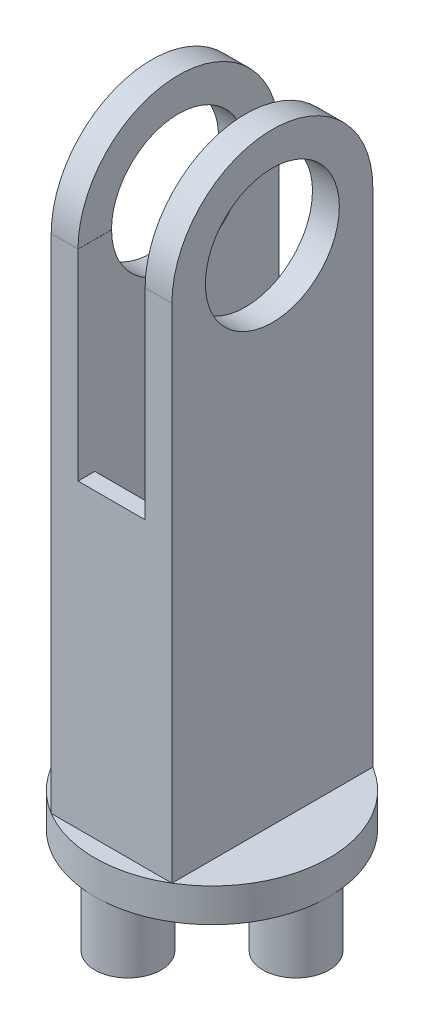
from build123d import *

# Parameters (mm, degrees)
SKETCH1_R            = 35
BOSS_EXTRUDE1_DEPTH  = 10
SKETCH3_R            = 9.9
BOSS_EXTRUDE2_DEPTH  = 19
SKETCH4_W            = 36.055512754
SKETCH4_H            = 60
BOSS_EXTRUDE8_DEPTH  = 150
SKETCH11_W           = 20
SKETCH11_H           = 60
CUT_EXTRUDE2_DEPTH   = 60
SKETCH12_W           = 20
SKETCH12_H           = 50
CUT_EXTRUDE3_DEPTH   = 90
SKETCH13_R           = 30
BOSS_EXTRUDE9_DEPTH  = 8
SKETCH14_R           = 30
BOSS_EXTRUDE10_DEPTH = 8
SKETCH15_R           = 20
CUT_EXTRUDE4_DEPTH   = 97


with BuildPart() as part:
    # Sketch1 → Boss-Extrude1 (new body)
    with BuildSketch(Plane(origin=(0, 0, 0), x_dir=(1, 0, 0), z_dir=(0, 1, 0))):
        Circle(SKETCH1_R)
    extrude(amount=BOSS_EXTRUDE1_DEPTH)

    # Sketch3 → Boss-Extrude2 (add)
    with BuildSketch(Plane.XZ):
        with Locations((25.1, 0)):
            Circle(SKETCH3_R)
        with Locations((0, -25.1)):
            Circle(SKETCH3_R)
        with Locations((-25.1, 0)):
            Circle(SKETCH3_R)
        with Locations((0, 25.1)):
            Circle(SKETCH3_R)
    extrude(amount=BOSS_EXTRUDE2_DEPTH)

    # Sketch4 → Boss-Extrude8 (add)
    with BuildSketch(Plane(origin=(0, 10, 0), x_dir=(1, 0, 0), z_dir=(0, 1, 0))):
        Rectangle(SKETCH4_W, SKETCH4_H)
    extrude(amount=BOSS_EXTRUDE8_DEPTH)

    # Sketch11 → Cut-Extrude2 (cut)
    with BuildSketch(Plane(origin=(0, 160, 0), x_dir=(1, 0, 0), z_dir=(0, 1, 0))):
        Rectangle(SKETCH11_W, SKETCH11_H)
    extrude(amount=-CUT_EXTRUDE2_DEPTH, mode=Mode.SUBTRACT)

    # Sketch12 → Cut-Extrude3 (cut)
    with BuildSketch(Plane(origin=(0, 100, 0), x_dir=(1, 0, 0), z_dir=(0, 1, 0))):
        Rectangle(SKETCH12_W, SKETCH12_H)
    extrude(amount=-CUT_EXTRUDE3_DEPTH, mode=Mode.SUBTRACT)

    # Sketch13 → Boss-Extrude9 (add)
    with BuildSketch(Plane.ZY.offset(18.027756377)):
        with Locations((0, 160)):
            Circle(SKETCH13_R)
    extrude(amount=-BOSS_EXTRUDE9_DEPTH)

    # Sketch14 → Boss-Extrude10 (add)
    with BuildSketch(Plane(origin=(18.027756377, 0, 0), x_dir=(0, 0, -1), z_dir=(1, 0, 0))):
        with Locations((0, 160)):
            Circle(SKETCH14_R)
    extrude(amount=-BOSS_EXTRUDE10_DEPTH)

    # Sketch15 → Cut-Extrude4 (cut)
    with BuildSketch(Plane(origin=(18.027756377, 0, 0), x_dir=(0, 0, -1), z_dir=(1, 0, 0))):
        with Locations((0, 160)):
            Circle(SKETCH15_R)
    extrude(amount=-CUT_EXTRUDE4_DEPTH, mode=Mode.SUBTRACT)


solid = part.part
